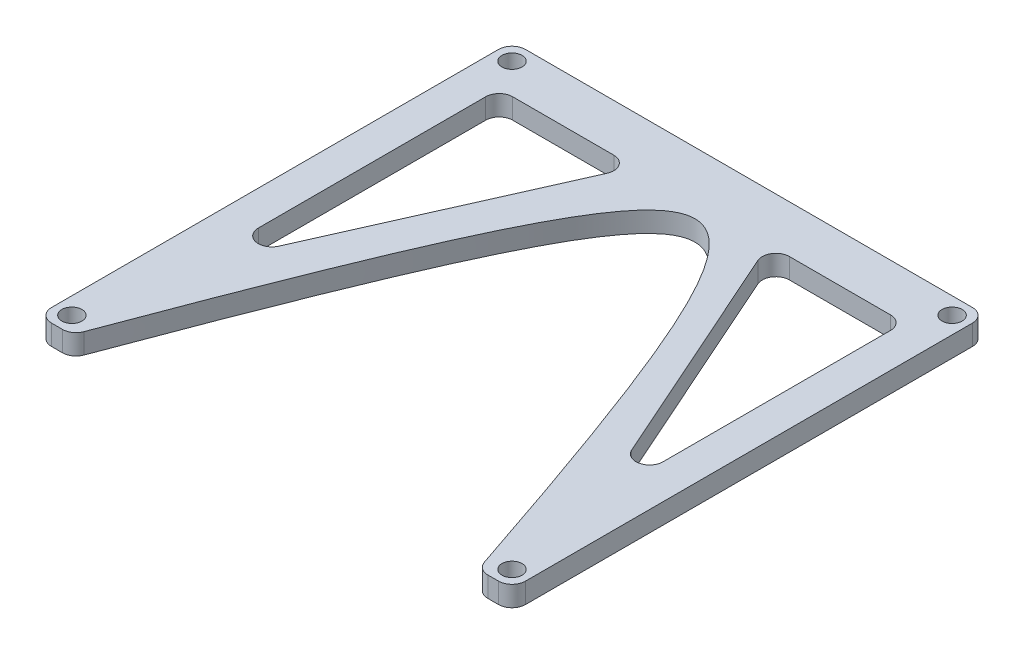
from build123d import *

# Parameters (mm, degrees)
BOSS_EXTRUDE1_DEPTH = 3
SKETCH3_R           = 1.488133846
CUT_EXTRUDE1_DEPTH  = 50.58830522
FILLET1_R           = 2
CUT_EXTRUDE2_DEPTH  = 50.58830522
FILLET2_R           = 2


with BuildPart() as part:
    # Sketch2 → Boss-Extrude1 (new body)
    with BuildSketch(Plane(origin=(0, 0, 0), x_dir=(1, 0, 0), z_dir=(0, 1, 0))):
        with BuildLine():
            Line((-30, -35), (-35, -35))
            Line((-35, -35), (-35, 35))
            Line((-35, 35), (35, 35))
            Line((35, 35), (35, -35))
            Line((35, -35), (30, -35))
            add(Edge.make_bspline(
                [(-30, -35), (1.60249835, 50.081530709), (30, -35)],
                knots=[0, 0, 0, 1, 1, 1], degree=2, weights=[1, 2.512958679, 1]))
        make_face()
    extrude(amount=BOSS_EXTRUDE1_DEPTH)

    # Sketch3 → Cut-Extrude1 (cut, through all)
    with BuildSketch(Plane(origin=(0, 3, 0), x_dir=(1, 0, 0), z_dir=(0, 1, 0))):
        with Locations(Location((-32.5, 32.5, 0), (0, 0, 270))):
            Circle(SKETCH3_R)
        with Locations(Location((32.5, 32.5, 0), (0, 0, 270))):
            Circle(SKETCH3_R)
        with Locations(Location((32.5, -32.5, 0), (0, 0, 270))):
            Circle(SKETCH3_R)
        with Locations(Location((-32.5, -32.5, 0), (0, 0, 270))):
            Circle(SKETCH3_R)
    extrude(amount=-CUT_EXTRUDE1_DEPTH, mode=Mode.SUBTRACT)

    # Fillet1
    fillet1_edges = [part.edges().sort_by_distance(p)[0] for p in [
        (35, 1.5, 35),
        (30, 1.5, 35),
        (-30, 1.5, 35),
        (-35, 1.5, 35),
        (-35, 1.5, -35),
        (35, 1.5, -35),
    ]]
    fillet(fillet1_edges, radius=FILLET1_R)

    # Sketch4 → Cut-Extrude2 (cut, through all)
    with BuildSketch(Plane(origin=(0, 3, 0), x_dir=(1, 0, 0), z_dir=(0, 1, 0))):
        Polygon((-29.891619327, -17), (-29.891619327, 28), (-9.891619327, 28), align=None)
        Polygon((29.891619327, -17), (29.891619327, 28), (9.891619327, 28), align=None)
    extrude(amount=-CUT_EXTRUDE2_DEPTH, mode=Mode.SUBTRACT)

    # Fillet2
    fillet2_edges = [part.edges().sort_by_distance(p)[0] for p in [
        (-9.891619327, 1.5, -28),
        (-29.891619327, 1.5, 17),
        (-29.891619327, 1.5, -28),
        (29.891619327, 1.5, 17),
        (9.891619327, 1.5, -28),
        (29.891619327, 1.5, -28),
    ]]
    fillet(fillet2_edges, radius=FILLET2_R)


solid = part.part
